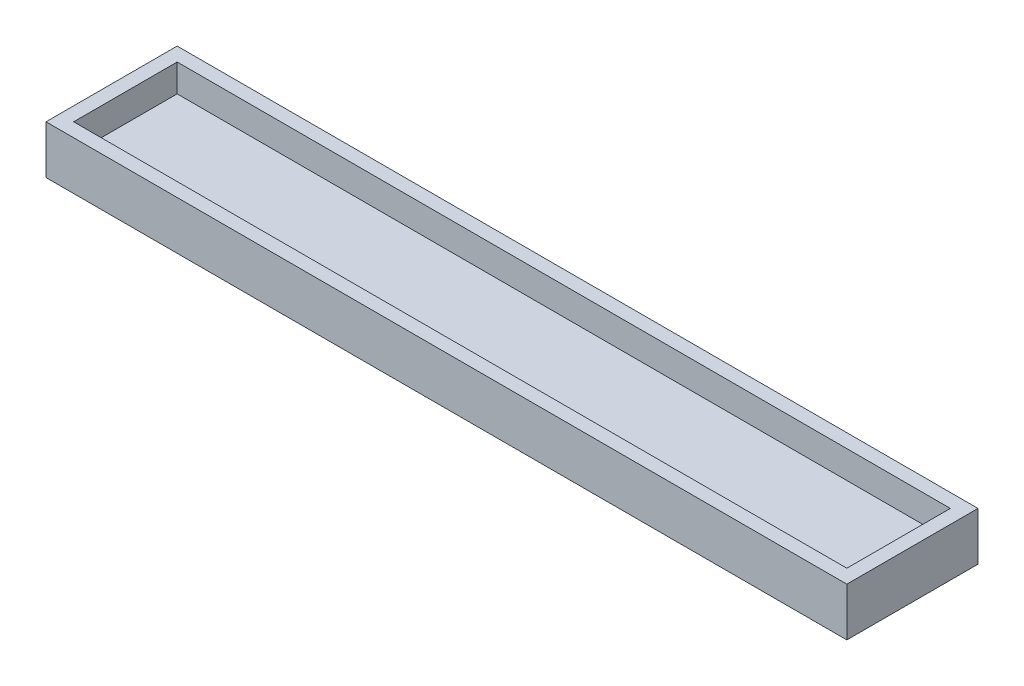
from build123d import *

# Parameters (mm, degrees)
SKETCH_1_W      = 112
SKETCH_1_H      = 15
EXTRUDE_1_DEPTH = 3
SKETCH_2_W      = 116
SKETCH_2_H      = 19
SKETCH_2_W_2    = 112
SKETCH_2_H_2    = 15
EXTRUDE_2_DEPTH = 7


with BuildPart() as part:
    # 草图1 → 凸台-拉伸1 (new body)
    with BuildSketch(Plane(origin=(0, 0, 0), x_dir=(1, 0, 0), z_dir=(0, 1, 0))):
        with Locations((56, -7.5)):
            Rectangle(SKETCH_1_W, SKETCH_1_H)
    extrude(amount=EXTRUDE_1_DEPTH)

    # 草图2 → 凸台-拉伸2 (add)
    with BuildSketch(Plane.XZ):
        with Locations((56, 7.5)):
            Rectangle(SKETCH_2_W, SKETCH_2_H)
        with Locations((56, 7.5)):
            Rectangle(SKETCH_2_W_2, SKETCH_2_H_2, mode=Mode.SUBTRACT)
    extrude(amount=-EXTRUDE_2_DEPTH)


solid = part.part
